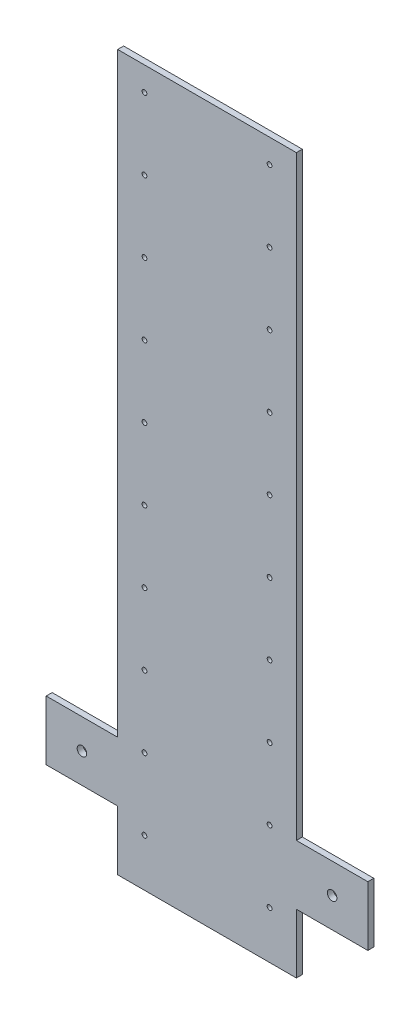
from build123d import *

# Parameters (mm, degrees)
SKETCH2_R           = 4
BOSS_EXTRUDE1_DEPTH = 5
SKETCH3_R           = 2
CUT_EXTRUDE1_DEPTH  = 5


with BuildPart() as part:
    # Sketch2 → Boss-Extrude1 (new body)
    with BuildSketch(Plane.XY):
        Polygon((75, 300), (75, -200), (135, -200), (135, -250), (75, -250), (75, -300), (-75, -300), (-75, -250), (-135, -250), (-135, -200), (-75, -200), (-75, 300), align=None)
        with Locations((-105, -225)):
            Circle(SKETCH2_R, mode=Mode.SUBTRACT)
        with Locations((105, -225)):
            Circle(SKETCH2_R, mode=Mode.SUBTRACT)
    extrude(amount=BOSS_EXTRUDE1_DEPTH)

    # Sketch3 → Cut-Extrude1 (cut)
    with BuildSketch(Plane.XY.offset(5)):
        with Locations((-52.5, 280)):
            Circle(SKETCH3_R)
        with Locations((-52.5, 220)):
            Circle(SKETCH3_R)
        with Locations((-52.5, 160)):
            Circle(SKETCH3_R)
        with Locations((-52.5, 100)):
            Circle(SKETCH3_R)
        with Locations((-52.5, 40)):
            Circle(SKETCH3_R)
        with Locations((-52.5, -20)):
            Circle(SKETCH3_R)
        with Locations((-52.5, -80)):
            Circle(SKETCH3_R)
        with Locations((-52.5, -140)):
            Circle(SKETCH3_R)
        with Locations((-52.5, -200)):
            Circle(SKETCH3_R)
        with Locations((-52.5, -260)):
            Circle(SKETCH3_R)
        with Locations((52.5, -260)):
            Circle(SKETCH3_R)
        with Locations((52.5, -200)):
            Circle(SKETCH3_R)
        with Locations((52.5, -140)):
            Circle(SKETCH3_R)
        with Locations((52.5, -80)):
            Circle(SKETCH3_R)
        with Locations((52.5, -20)):
            Circle(SKETCH3_R)
        with Locations((52.5, 40)):
            Circle(SKETCH3_R)
        with Locations((52.5, 100)):
            Circle(SKETCH3_R)
        with Locations((52.5, 160)):
            Circle(SKETCH3_R)
        with Locations((52.5, 220)):
            Circle(SKETCH3_R)
        with Locations((52.5, 280)):
            Circle(SKETCH3_R)
    extrude(amount=-CUT_EXTRUDE1_DEPTH, mode=Mode.SUBTRACT)


solid = part.part
